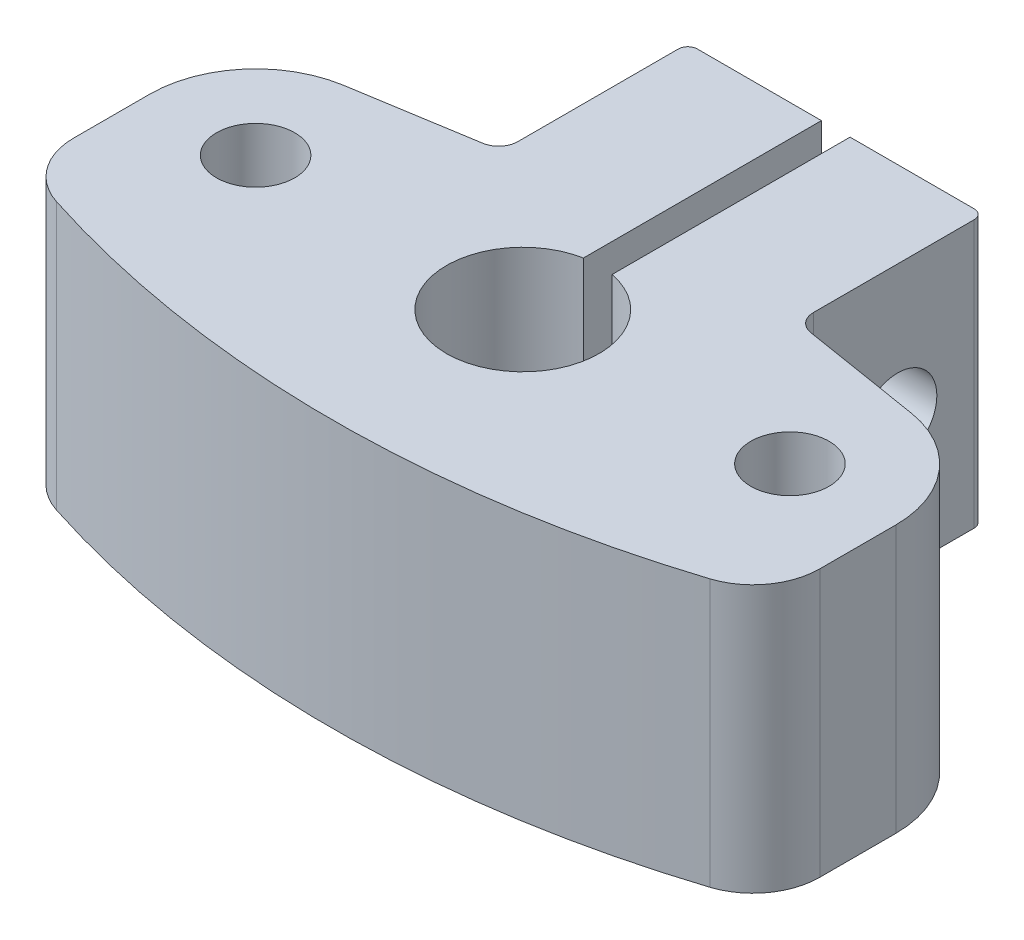
from build123d import *

# Parameters (mm, degrees)
SKETCH1_R           = 2.05
BOSS_EXTRUDE1_DEPTH = 14
SKETCH2_R           = 2.05
CUT_EXTRUDE1_DEPTH  = 28.3


with BuildPart() as part:
    # Sketch1 → Boss-Extrude1 (new body)
    with BuildSketch(Plane(origin=(0, 0, 0), x_dir=(1, 0, 0), z_dir=(0, 1, 0))):
        with BuildLine():
            Line((-19.55, 0), (-19.55, -3.98647317))
            ThreePointArc((-19.55, -3.98647317), (-18.877985148, -6.048632233), (-17.12, -7.318904715))
            ThreePointArc((-17.12, -7.318904715), (0, -10), (17.12, -7.318904715))
            ThreePointArc((17.12, -7.318904715), (18.877985148, -6.048632233), (19.55, -3.98647317))
            Line((19.55, -3.98647317), (19.55, 0))
            ThreePointArc((19.55, 0), (18.22693576, 3.59659757), (14.888553485, 5.478409687))
            Line((14.888553485, 5.478409687), (8.589900273, 6.5))
            ThreePointArc((8.589900273, 6.5), (7.988389953, 6.839065246), (7.75, 7.487100845))
            Line((7.75, 7.487100845), (7.75, 15.9))
            ThreePointArc((7.75, 15.9), (7.603553391, 16.253553391), (7.25, 16.4))
            Line((7.25, 16.4), (0.75, 16.4))
            Line((0.75, 16.4), (0.75, 3.929058411))
            ThreePointArc((0.75, 3.929058411), (0, -4), (-0.75, 3.929058411))
            Line((-0.75, 3.929058411), (-0.75, 16.4))
            Line((-0.75, 16.4), (-7.25, 16.4))
            ThreePointArc((-7.25, 16.4), (-7.603553391, 16.253553391), (-7.75, 15.9))
            Line((-7.75, 15.9), (-7.75, 7.487100845))
            ThreePointArc((-7.75, 7.487100845), (-7.988389953, 6.839065246), (-8.589900273, 6.5))
            Line((-8.589900273, 6.5), (-14.888553485, 5.478409687))
            ThreePointArc((-14.888553485, 5.478409687), (-18.22693576, 3.59659757), (-19.55, 0))
        make_face()
        with Locations((-14, 0)):
            Circle(SKETCH1_R, mode=Mode.SUBTRACT)
        with Locations((14, 0)):
            Circle(SKETCH1_R, mode=Mode.SUBTRACT)
    extrude(amount=BOSS_EXTRUDE1_DEPTH)

    # Sketch2 → Cut-Extrude1 (cut, through all)
    with BuildSketch(Plane(origin=(7.75, 0, 0), x_dir=(0, 0, -1), z_dir=(1, 0, 0))):
        with Locations((11.9, 7)):
            Circle(SKETCH2_R)
    extrude(amount=-CUT_EXTRUDE1_DEPTH, mode=Mode.SUBTRACT)


solid = part.part
